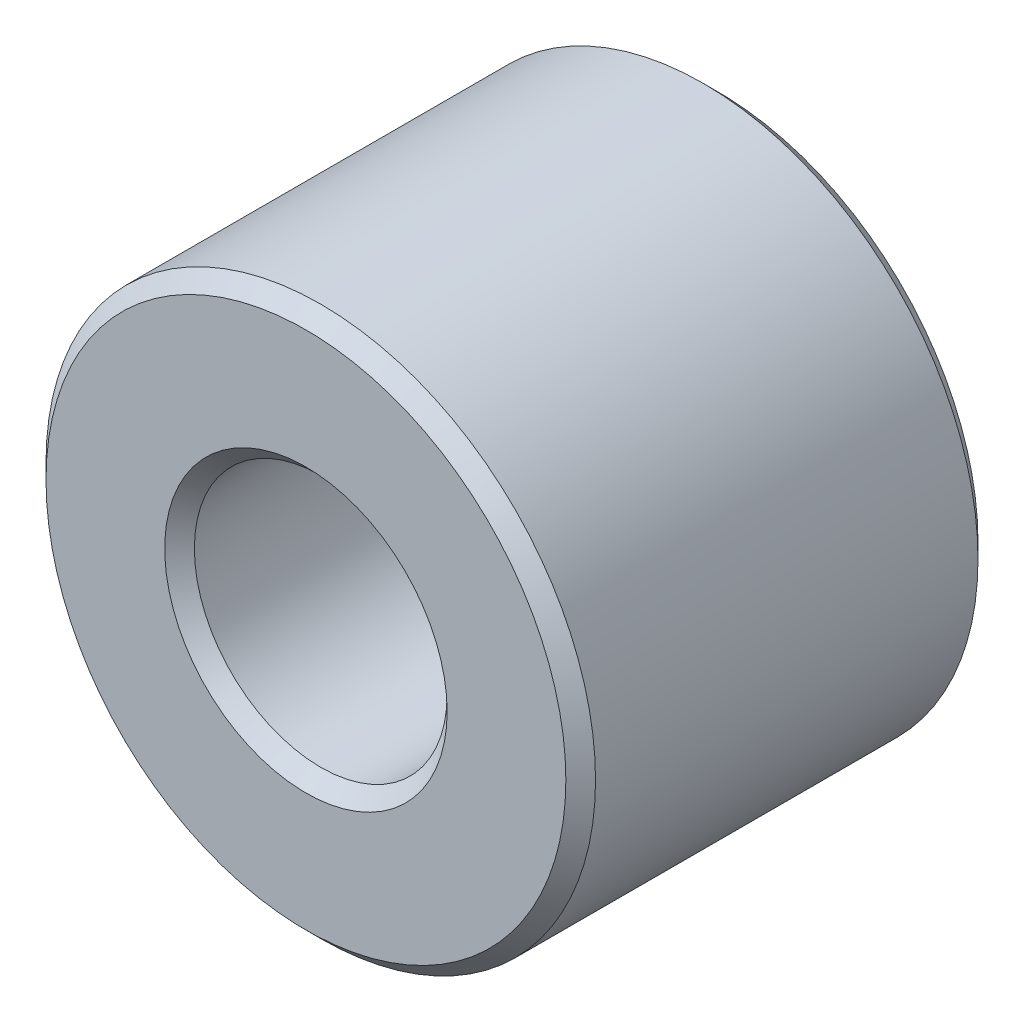
from build123d import *

# Parameters (mm, degrees)
BOSS_EXTRUDE1_DEPTH      = 2.38125
BOSS_EXTRUDE1_DEPTH_BACK = 2.38125
SKETCH3_R                = 3.175
SKETCH3_R_2              = 1.4605
CHAMFER1_SIZE            = 0.17145


with BuildPart() as part:
    # Sketch3 → Boss-Extrude1 (new, two sides: drawn at the far end of the back side and taken through both)
    with BuildSketch(Plane.XY.offset(-BOSS_EXTRUDE1_DEPTH_BACK)):
        Circle(SKETCH3_R)
        Circle(SKETCH3_R_2, mode=Mode.SUBTRACT)
    extrude(amount=BOSS_EXTRUDE1_DEPTH + BOSS_EXTRUDE1_DEPTH_BACK)

    # Chamfer1
    chamfer1_edges = [part.edges().sort_by_distance(p)[0] for p in [
        (-3.175, 0, -2.38125),
        (-1.4605, 0, -2.38125),
        (-3.175, 0, 2.38125),
        (-1.4605, 0, 2.38125),
    ]]
    chamfer(chamfer1_edges, length=CHAMFER1_SIZE)


solid = part.part
